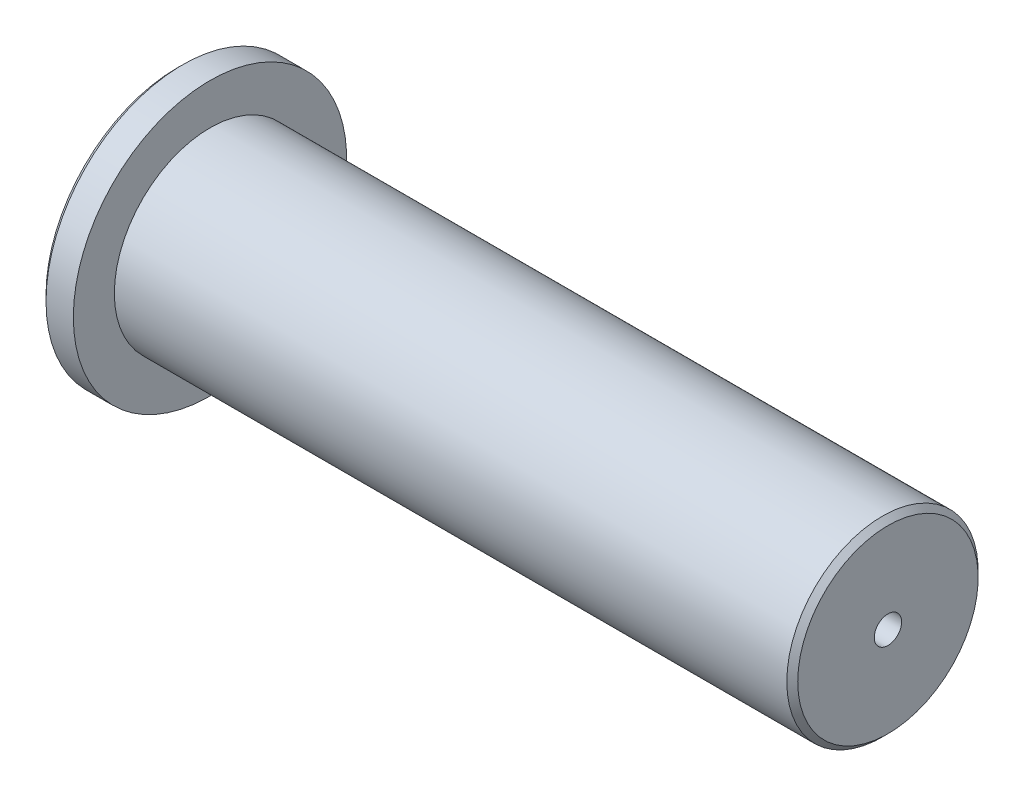
from build123d import *

# Parameters (mm, degrees)
HOLE_WIZARD_M6_1_D     = 5
HOLE_WIZARD_M6_1_DEPTH = 15
HOLE_WIZARD_M6_1_TIP   = 1.502151548


with BuildPart() as part:
    # 草图1 → 旋转1 (revolve)
    with BuildSketch(Plane.XY):
        Polygon((-4236.178380328, -7413.983238222), (-4106.178380328, -7413.983238222), (-4106.178380328, -7397.483238222), (-4107.178380328, -7396.483238222), (-4230.178380328, -7396.483238222), (-4230.178380328, -7388.983238222), (-4235.178380328, -7388.983238222), (-4236.178380328, -7389.983238222), align=None)
    revolve(axis=Axis((-4215.718625876, -7413.983238222, 0), (1, 0, 0)))

    # M6 螺纹孔的螺纹孔钻头1
    with Locations(Plane(origin=(-4106.178380328, 0, 0), x_dir=(0, 0, -1), z_dir=(1, 0, 0))):
        with Locations((0, -7413.983238222)):
            Hole(HOLE_WIZARD_M6_1_D / 2, depth=HOLE_WIZARD_M6_1_DEPTH)
            with Locations((0, 0, -(HOLE_WIZARD_M6_1_DEPTH + HOLE_WIZARD_M6_1_TIP / 2))):  # 118° drill point
                Cone(0, HOLE_WIZARD_M6_1_D / 2, HOLE_WIZARD_M6_1_TIP, mode=Mode.SUBTRACT)


solid = part.part
